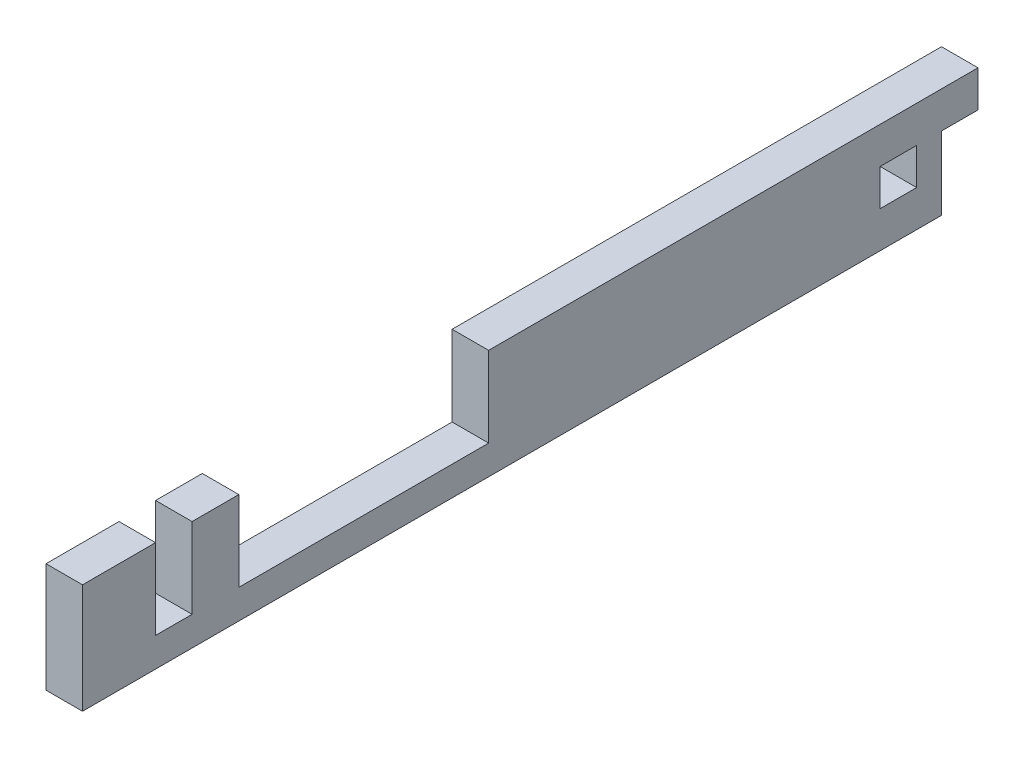
from build123d import *

# Parameters (mm, degrees)
BOSS_EXTRUDE1_DEPTH = 19.05
SKETCH2_W           = 43.434
SKETCH2_H           = 13.97
MOTOR_HOLE_DEPTH    = 19.05
SKETCH3_W           = 6.35
SKETCH3_H           = 12.7
CUT_EXTRUDE2_DEPTH  = 36.941
SKETCH5_W           = 6.35
SKETCH5_H           = 13.97
SKETCH5_H_2         = 6.35
CUT_EXTRUDE6_DEPTH  = 36.941
SKETCH7_W           = 50.257507562
SKETCH7_H           = 159.787423729
CUT_EXTRUDE7_DEPTH  = 20.05


with BuildPart() as part:
    # Sketch1 → Boss-Extrude1 (new body)
    with BuildSketch(Plane(origin=(0, 0, 0), x_dir=(1, 0, 0), z_dir=(0, 1, 0))):
        Polygon((-10.033, 66.167), (-11.6205, 66.167), (-11.6205, 76.835), (-17.9705, 76.835), (-17.9705, -78.867), (-11.6205, -78.867), (-11.6205, -66.167), (11.6205, -66.167), (11.6205, -78.867), (17.9705, -78.867), (17.9705, 76.835), (11.6205, 76.835), (11.6205, 66.167), (10.033, 66.167), (10.033, 59.817), (11.6205, 59.817), (11.6205, -59.817), (-11.6205, -59.817), (-11.6205, 59.817), (-10.033, 59.817), align=None)
    extrude(amount=BOSS_EXTRUDE1_DEPTH)

    # Sketch2 → Motor Hole (cut)
    with BuildSketch(Plane.ZY.offset(17.9705)):
        with Locations((29.972, 12.065)):
            Rectangle(SKETCH2_W, SKETCH2_H)
    extrude(amount=-MOTOR_HOLE_DEPTH, mode=Mode.SUBTRACT)

    # Sketch3 → Cut-Extrude2 (cut, through all)
    with BuildSketch(Plane.ZY.offset(17.9705)):
        with Locations((-73.66, 6.35)):
            Rectangle(SKETCH3_W, SKETCH3_H)
    extrude(amount=-CUT_EXTRUDE2_DEPTH, mode=Mode.SUBTRACT)

    # Sketch5 → Cut-Extrude6 (cut, through all)
    with BuildSketch(Plane.ZY.offset(17.9705)):
        with Locations((62.992, 12.065)):
            Rectangle(SKETCH5_W, SKETCH5_H)
        with Locations((-62.992, 9.525)):
            Rectangle(SKETCH5_W, SKETCH5_H_2)
    extrude(amount=-CUT_EXTRUDE6_DEPTH, mode=Mode.SUBTRACT)

    # Sketch7 → Cut-Extrude7 (cut, through all)
    with BuildSketch(Plane(origin=(0, 0, 0), x_dir=(1, 0, 0), z_dir=(0, 1, 0))):
        with Locations((13.508253781, 1.026711865)):
            Rectangle(SKETCH7_W, SKETCH7_H)
    extrude(amount=CUT_EXTRUDE7_DEPTH, mode=Mode.SUBTRACT)


solid = part.part
